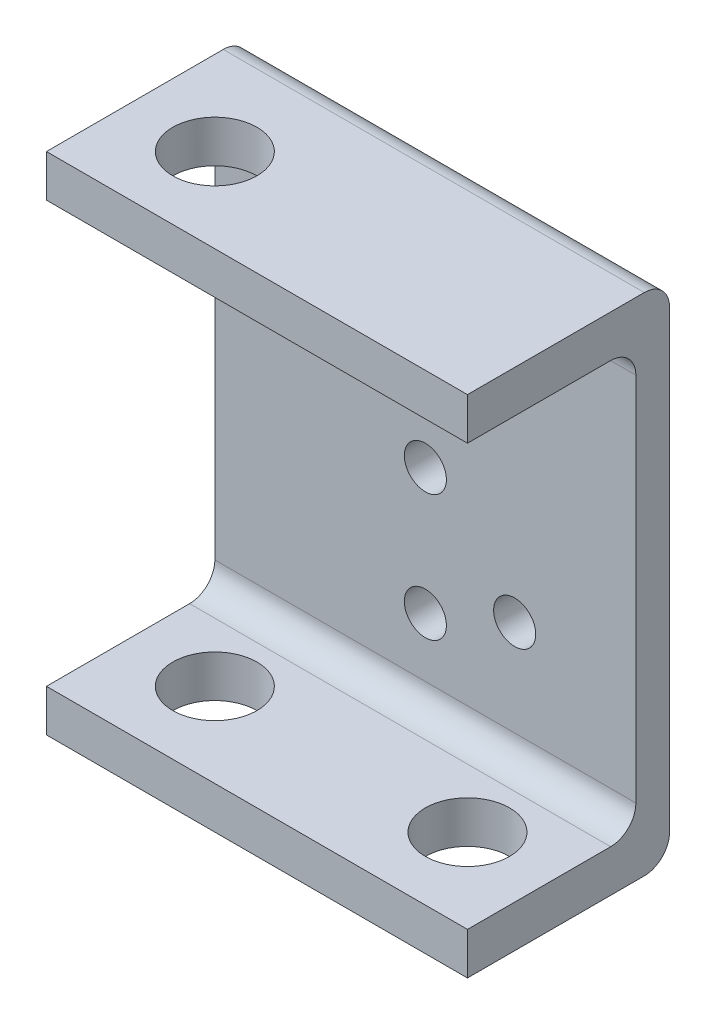
from build123d import *

# Parameters (mm, degrees)
BOSS_EXTRUDE1_DEPTH = 25
SKETCH2_R           = 2.5
CUT_EXTRUDE1_DEPTH  = 4
SKETCH5_R           = 5
CUT_EXTRUDE2_DEPTH  = 60
SKETCH5_3_R         = 5
CUT_EXTRUDE3_DEPTH  = 5


with BuildPart() as part:
    # Sketch1 → Boss-Extrude1 (new body, symmetric)
    with BuildSketch(Plane(origin=(0, 0, 0), x_dir=(0, 0, -1), z_dir=(1, 0, 0))):
        with BuildLine():
            Line((0, 27), (0, -27))
            ThreePointArc((0, -27), (-0.878679656, -29.121320344), (-3, -30))
            Line((-3, -30), (-24, -30))
            Line((-24, -30), (-24, -25))
            Line((-24, -25), (-7, -25))
            ThreePointArc((-7, -25), (-4.878679656, -24.121320344), (-4, -22))
            Line((-4, -22), (-4, 22))
            ThreePointArc((-4, 22), (-4.878679656, 24.121320344), (-7, 25))
            Line((-7, 25), (-24, 25))
            Line((-24, 25), (-24, 30))
            Line((-24, 30), (-3, 30))
            ThreePointArc((-3, 30), (-0.878679656, 29.121320344), (0, 27))
        make_face()
    extrude(amount=BOSS_EXTRUDE1_DEPTH, both=True)

    # Sketch2 → Cut-Extrude1 (cut)
    with BuildSketch(Plane(origin=(0, 0, 0), x_dir=(-1, 0, 0), z_dir=(0, 0, -1))):
        Circle(SKETCH2_R)
        with Locations((0, 15)):
            Circle(SKETCH2_R)
        with Locations((10.606601718, 10.606601718)):
            Circle(SKETCH2_R)
        with Locations((-10.606601718, -10.606601718)):
            Circle(SKETCH2_R)
        with Locations((0, -15)):
            Circle(SKETCH2_R)
    extrude(amount=-CUT_EXTRUDE1_DEPTH, mode=Mode.SUBTRACT)

    # Sketch5 → Cut-Extrude2 (cut)
    with BuildSketch(Plane.XZ.offset(30)):
        with Locations((-15, 14)):
            Circle(SKETCH5_R)
    extrude(amount=-CUT_EXTRUDE2_DEPTH, mode=Mode.SUBTRACT)

    # Sketch5_3 → Cut-Extrude3 (cut)
    with BuildSketch(Plane.XZ.offset(30)):
        with Locations((15, 14)):
            Circle(SKETCH5_3_R)
    extrude(amount=-CUT_EXTRUDE3_DEPTH, mode=Mode.SUBTRACT)


solid = part.part
